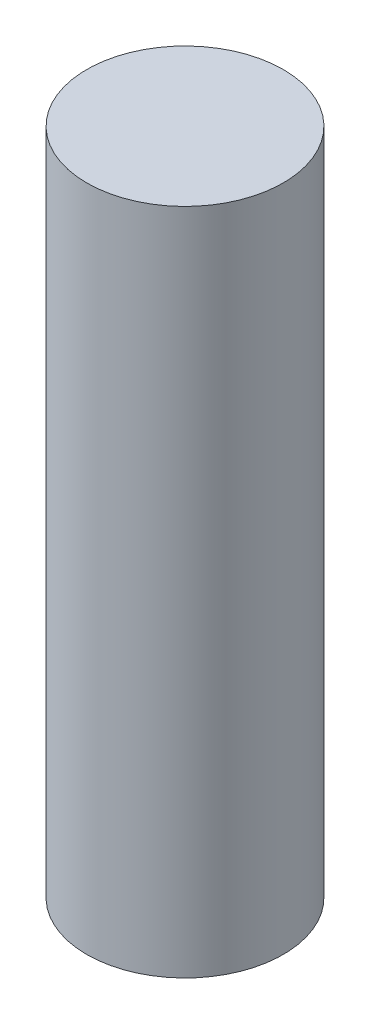
from build123d import *

# Parameters (mm, degrees)
SKETCH1_R           = 12.5
BOSS_EXTRUDE1_DEPTH = 85


with BuildPart() as part:
    # Sketch1 → Boss-Extrude1 (new body)
    with BuildSketch(Plane(origin=(0, 0, 0), x_dir=(1, 0, 0), z_dir=(0, 1, 0))):
        Circle(SKETCH1_R)
    extrude(amount=BOSS_EXTRUDE1_DEPTH)


solid = part.part
